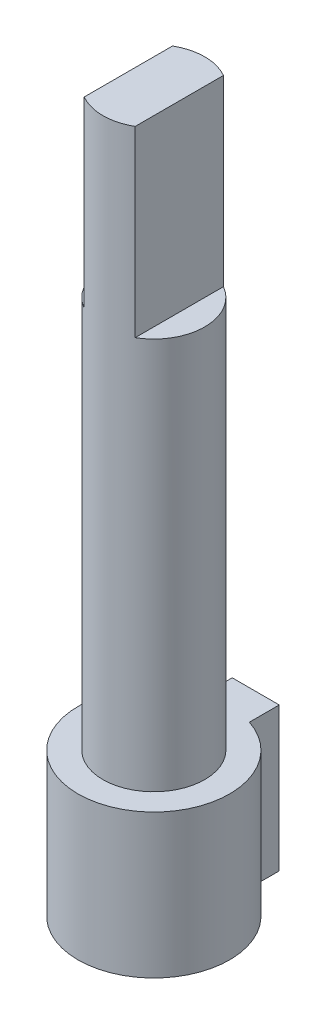
from build123d import *

# Parameters (mm, degrees)
SKETCH1_R           = 3
SKETCH1_W           = 2
SKETCH1_H           = 1.17
BOSS_EXTRUDE1_DEPTH = 27.5
SKETCH2_R           = 6.166150273
SKETCH2_R_2         = 1.95
CUT_EXTRUDE1_DEPTH  = 22
CUT_EXTRUDE2_DEPTH  = 7
CUT_EXTRUDE3_DEPTH  = 100


with BuildPart() as part:
    # Sketch1 → Boss-Extrude1 (new body)
    with BuildSketch(Plane(origin=(0, 0, 0), x_dir=(1, 0, 0), z_dir=(0, 1, 0))):
        Circle(SKETCH1_R)
        with Locations((0, 3.413427125)):
            Rectangle(SKETCH1_W, SKETCH1_H)
    extrude(amount=BOSS_EXTRUDE1_DEPTH)

    # Sketch2 → Cut-Extrude1 (cut)
    with BuildSketch(Plane(origin=(0, 27.5, 0), x_dir=(1, 0, 0), z_dir=(0, 1, 0))):
        Circle(SKETCH2_R)
        Circle(SKETCH2_R_2, mode=Mode.SUBTRACT)
    extrude(amount=-CUT_EXTRUDE1_DEPTH, mode=Mode.SUBTRACT)

    # Sketch3 → Cut-Extrude2 (cut)
    with BuildSketch(Plane(origin=(0, 27.5, 0), x_dir=(1, 0, 0), z_dir=(0, 1, 0))):
        with BuildLine():
            Line((-0.975, 1.688749537), (-0.975, -1.688749537))
            ThreePointArc((-0.975, -1.688749537), (-1.95, 0), (-0.975, 1.688749537))
        make_face()
        with BuildLine():
            Line((0.975, 1.688749537), (0.975, -1.688749537))
            ThreePointArc((0.975, -1.688749537), (1.95, 0), (0.975, 1.688749537))
        make_face()
    extrude(amount=-CUT_EXTRUDE2_DEPTH, mode=Mode.SUBTRACT)

    # Sketch4 → Cut-Extrude3 (cut)
    with BuildSketch(Plane.XZ):
        with BuildLine():
            Line((-1, -3.998427125), (1, -3.998427125))
            Line((1, -3.998427125), (1, -2.828427125))
            ThreePointArc((1, -2.828427125), (0, 3), (-1, -2.828427125))
            Line((-1, -2.828427125), (-1, -3.998427125))
        make_face()
        with BuildLine():
            Line((-0.9, -2.75680975), (-0.9, -3.898427125))
            Line((-0.9, -3.898427125), (0.9, -3.898427125))
            Line((0.9, -3.898427125), (0.9, -2.75680975))
            ThreePointArc((0.9, -2.75680975), (0, 2.9), (-0.9, -2.75680975))
        make_face(mode=Mode.SUBTRACT)
    extrude(amount=-CUT_EXTRUDE3_DEPTH, mode=Mode.SUBTRACT)


solid = part.part
